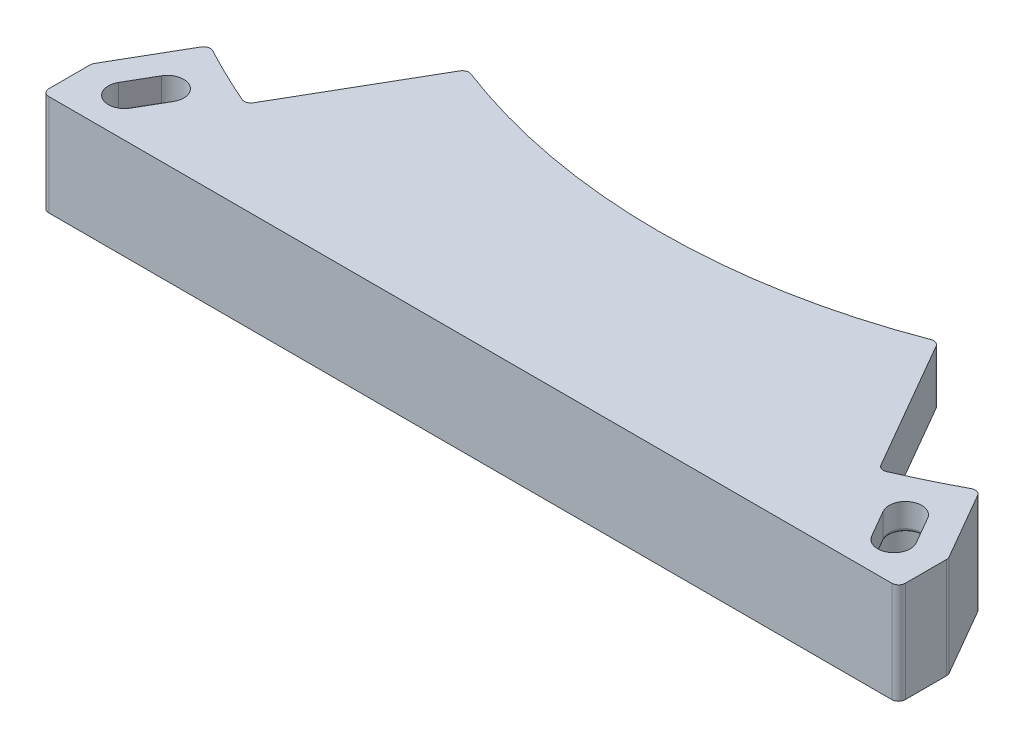
from build123d import *

# Parameters (mm, degrees)
BOSS_EXTRUDE1_DEPTH = 15
CUT_EXTRUDE1_DEPTH  = 16
CUT_EXTRUDE3_START  = -4
CUT_EXTRUDE3_DEPTH  = 12
FILLET2_R           = 0.5
BOSS_EXTRUDE2_DEPTH = 8
SKETCH5_W           = 10.5
SKETCH5_H           = 10.5
CUT_EXTRUDE4_DEPTH  = 7
CUT_EXTRUDE5_DEPTH  = 16
FILLET1_R           = 1


with BuildPart() as part:
    # Sketch1 → Boss-Extrude1 (new body)
    with BuildSketch(Plane(origin=(0, 0, 0), x_dir=(1, 0, 0), z_dir=(0, 1, 0))):
        with BuildLine():
            Line((-57.286267839, -105.443271559), (-68, -124))
            Line((-68, -124), (68, -124))
            Line((68, -124), (57.286267839, -105.443271559))
            ThreePointArc((57.286267839, -105.443271559), (0, -120), (-57.286267839, -105.443271559))
        make_face()
    extrude(amount=BOSS_EXTRUDE1_DEPTH)

    # Sketch2 → Cut-Extrude1 (cut, through all)
    with BuildSketch(Plane(origin=(0, 15, 0), x_dir=(1, 0, 0), z_dir=(0, 1, 0))):
        with BuildLine():
            Line((-52.804159001, -115.380031326), (-55.129159001, -119.407049454))
            ThreePointArc((-55.129159001, -119.407049454), (-58.441770605, -120.294661058), (-59.32938221, -116.982049454))
            Line((-59.32938221, -116.982049454), (-57.00438221, -112.955031326))
            ThreePointArc((-57.00438221, -112.955031326), (-53.691770605, -112.067419722), (-52.804159001, -115.380031326))
        make_face()
        with BuildLine():
            Line((52.804159001, -115.380031326), (55.129159001, -119.407049454))
            ThreePointArc((55.129159001, -119.407049454), (58.441770605, -120.294661058), (59.32938221, -116.982049454))
            Line((59.32938221, -116.982049454), (57.00438221, -112.955031326))
            ThreePointArc((57.00438221, -112.955031326), (53.691770605, -112.067419722), (52.804159001, -115.380031326))
        make_face()
    extrude(amount=-CUT_EXTRUDE1_DEPTH, mode=Mode.SUBTRACT)

    # Sketch3 → Cut-Extrude3 (cut, through all)
    with BuildSketch(Plane(origin=(0, 15, 0), x_dir=(1, 0, 0), z_dir=(0, 1, 0)).offset(CUT_EXTRUDE3_START)):
        with BuildLine():
            Line((-51.019656288, -116.439181962), (-53.319656288, -120.422898819))
            ThreePointArc((-53.319656288, -120.422898819), (-59.466770605, -122.070013136), (-61.113884922, -115.922898819))
            Line((-61.113884922, -115.922898819), (-58.813884922, -111.939181962))
            ThreePointArc((-58.813884922, -111.939181962), (-52.666770605, -110.292067644), (-51.019656288, -116.439181962))
        make_face()
        with BuildLine():
            Line((51.019656288, -116.439181962), (53.319656288, -120.422898819))
            ThreePointArc((53.319656288, -120.422898819), (59.466770605, -122.070013136), (61.113884922, -115.922898819))
            Line((61.113884922, -115.922898819), (58.813884922, -111.939181962))
            ThreePointArc((58.813884922, -111.939181962), (52.666770605, -110.292067644), (51.019656288, -116.439181962))
        make_face()
    extrude(amount=-CUT_EXTRUDE3_DEPTH, mode=Mode.SUBTRACT)

    # Fillet2
    fillet2_edges = [part.edges().sort_by_distance(p)[0] for p in [
        (-58.16688221, 11, 114.96854039),
        (53.966659001, 11, 117.39354039),
        (-52.666770605, 11, 110.292067644),
        (-59.963884922, 11, 113.93104039),
        (-59.466770605, 11, 122.070013136),
        (-52.169656288, 11, 118.43104039),
        (-53.691770605, 11, 112.067419722),
        (-53.966659001, 11, 117.39354039),
        (-58.441770605, 11, 120.294661058),
        (52.666770605, 11, 110.292067644),
        (52.169656288, 11, 118.43104039),
        (59.466770605, 11, 122.070013136),
        (59.963884922, 11, 113.93104039),
        (58.16688221, 11, 114.96854039),
        (53.691770605, 11, 112.067419722),
        (58.441770605, 11, 120.294661058),
    ]]
    fillet(fillet2_edges, radius=FILLET2_R)

    # Sketch4 → Boss-Extrude2 (add)
    with BuildSketch(Plane(origin=(0, 15, 0), x_dir=(1, 0, 0), z_dir=(0, 1, 0))):
        with BuildLine():
            Line((-35.015731887, -89.386232276), (-55, -124))
            Line((-55, -124), (55, -124))
            Line((55, -124), (35.015731887, -89.386232276))
            ThreePointArc((35.015731887, -89.386232276), (0, -96), (-35.015731887, -89.386232276))
        make_face()
    extrude(amount=-BOSS_EXTRUDE2_DEPTH)

    # Sketch5 → Cut-Extrude4 (cut)
    with BuildSketch(Plane.XZ.offset(-7)):
        with Locations((0, 108)):
            Rectangle(SKETCH5_W, SKETCH5_H)
        Polygon((17.998277994, 101.297517192), (20.360264064, 111.528402872), (30.591149745, 109.166416802), (28.229163674, 98.935531121), align=None)
        Polygon((-17.998277994, 101.297517192), (-20.360264064, 111.528402872), (-30.591149745, 109.166416802), (-28.229163674, 98.935531121), align=None)
    extrude(amount=-CUT_EXTRUDE4_DEPTH, mode=Mode.SUBTRACT)

    # Sketch6 → Cut-Extrude5 (cut, through all)
    with BuildSketch(Plane.XZ):
        Polygon((63.716770605, 116.581229068), (63.716770605, 124), (68, 124), align=None)
        Polygon((-68, 124), (-63.716770605, 116.581229068), (-63.716770605, 124), align=None)
    extrude(amount=-CUT_EXTRUDE5_DEPTH, mode=Mode.SUBTRACT)

    # Fillet1
    fillet1_edges = [part.edges().sort_by_distance(p)[0] for p in [
        (35.015731887, 11, 89.386232276),
        (-35.015731887, 11, 89.386232276),
        (47.124753912, 11, 110.359673653),
        (-47.124753912, 11, 110.359673653),
        (63.716770605, 7.5, 116.581229068),
        (63.716770605, 7.5, 124),
        (-63.716770605, 7.5, 124),
        (-63.716770605, 7.5, 116.581229068),
        (57.286267839, 7.5, 105.443271559),
        (-57.286267839, 7.5, 105.443271559),
    ]]
    fillet(fillet1_edges, radius=FILLET1_R)


solid = part.part
